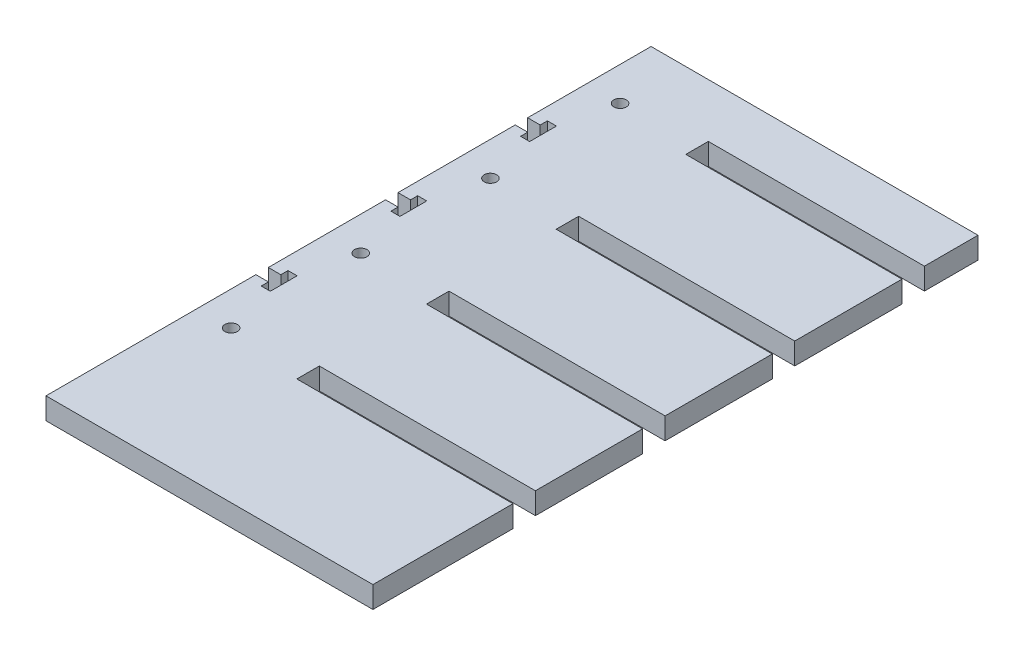
from build123d import *

# Parameters (mm, degrees)
SKETCH1_R           = 1.8288
BOSS_EXTRUDE1_DEPTH = 6.35


with BuildPart() as part:
    # Sketch1 → Boss-Extrude1 (new body)
    with BuildSketch(Plane(origin=(0, 0, 0), x_dir=(1, 0, 0), z_dir=(0, 1, 0))):
        Polygon((-48.0314, 88.9), (48.0314, 88.9), (48.0314, 73.152), (-15.4686, 73.152), (-15.4686, 66.548), (48.0314, 66.548), (48.0314, 35.052), (-15.4686, 35.052), (-15.4686, 28.448), (48.0314, 28.448), (48.0314, -3.048), (-15.4686, -3.048), (-15.4686, -9.652), (48.0314, -9.652), (48.0314, -41.148), (-15.4686, -41.148), (-15.4686, -47.752), (48.0314, -47.752), (48.0314, -88.9), (-48.0314, -88.9), (-48.0314, -27.2288), (-44.3484, -27.2288), (-44.3484, -29.337), (-41.6814, -29.337), (-41.6814, -21.463), (-44.3484, -21.463), (-44.3484, -23.5712), (-48.0314, -23.5712), (-48.0314, 10.8712), (-44.3484, 10.8712), (-44.3484, 8.763), (-41.6814, 8.763), (-41.6814, 16.637), (-44.3484, 16.637), (-44.3484, 14.5288), (-48.0314, 14.5288), (-48.0314, 48.9712), (-44.3484, 48.9712), (-44.3484, 46.863), (-41.6814, 46.863), (-41.6814, 54.737), (-44.3484, 54.737), (-44.3484, 52.6288), (-48.0314, 52.6288), align=None)
        with Locations((-38.1, 69.85)):
            Circle(SKETCH1_R, mode=Mode.SUBTRACT)
        with Locations((-38.1, 31.75)):
            Circle(SKETCH1_R, mode=Mode.SUBTRACT)
        with Locations((-38.1, -6.35)):
            Circle(SKETCH1_R, mode=Mode.SUBTRACT)
        with Locations((-38.1, -44.45)):
            Circle(SKETCH1_R, mode=Mode.SUBTRACT)
    extrude(amount=-BOSS_EXTRUDE1_DEPTH)


solid = part.part
